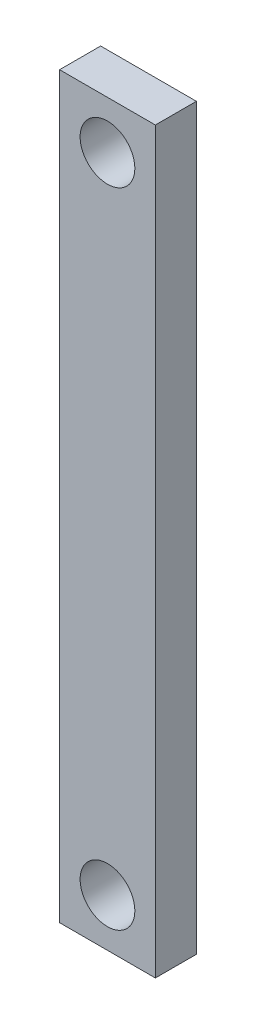
from build123d import *

# Parameters (mm, degrees)
SKETCH1_W              = 35
SKETCH1_H              = 270
BOSS_EXTRUDE1_DEPTH    = 15
F_20_0MM_DOWEL_HOLE1_D = 20


with BuildPart() as part:
    # Sketch1 → Boss-Extrude1 (new body)
    with BuildSketch(Plane.XY):
        with Locations((-17.5, -135)):
            Rectangle(SKETCH1_W, SKETCH1_H)
    extrude(amount=BOSS_EXTRUDE1_DEPTH)

    # Ø20.0mm Dowel Hole1 (through all)
    with Locations(Plane.XY.offset(15)):
        with Locations((-17.5, -17.5), (-17.5, -252.5)):
            Hole(F_20_0MM_DOWEL_HOLE1_D / 2)


solid = part.part
